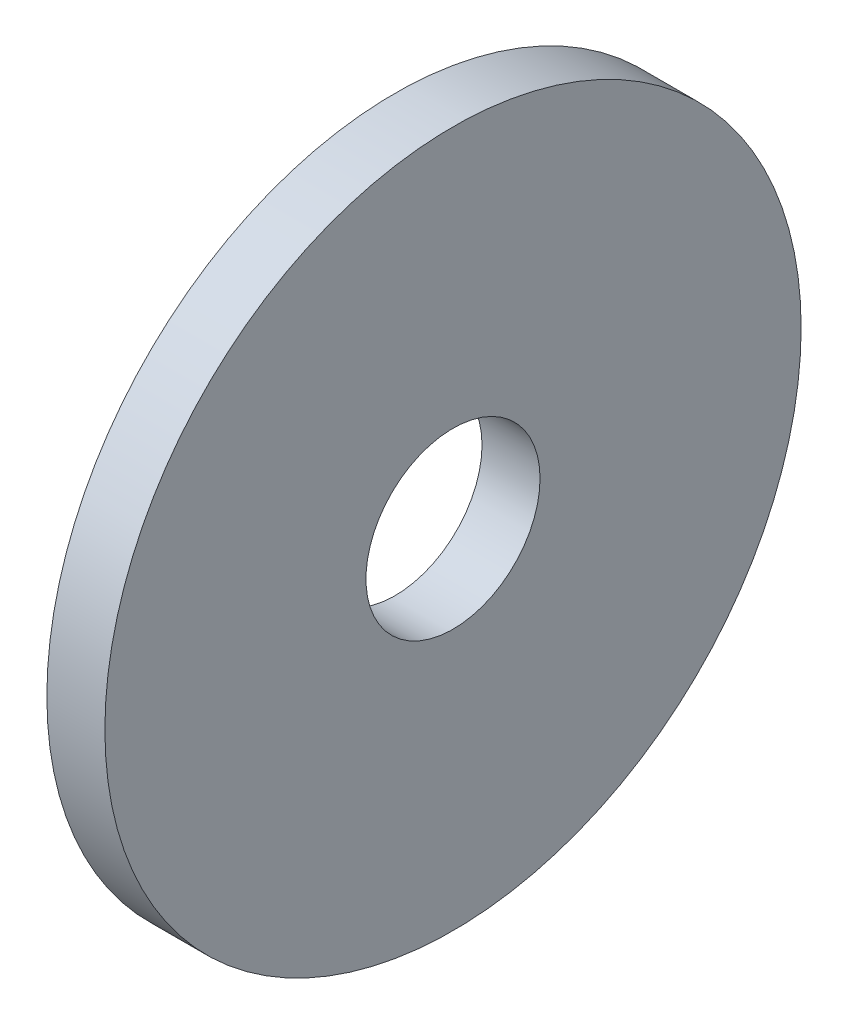
from build123d import *

# Parameters (mm, degrees)
SKETCH1_R               = 12
BOSS_EXTRUDE1_DEPTH     = 2
SKETCH2_R               = 3
CUT_EXTRUDE1_DEPTH      = 1
CUT_EXTRUDE1_DEPTH_BACK = 3


with BuildPart() as part:
    # Sketch1 → Boss-Extrude1 (new body)
    with BuildSketch(Plane(origin=(0, 0, 0), x_dir=(0, 0, -1), z_dir=(1, 0, 0))):
        Circle(SKETCH1_R)
    extrude(amount=BOSS_EXTRUDE1_DEPTH)

    # Sketch2 → Cut-Extrude1 (cut, two sides)
    with BuildSketch(Plane(origin=(2, 0, 0), x_dir=(0, 0, -1), z_dir=(1, 0, 0))) as cut_extrude1_sk:
        Circle(SKETCH2_R)
    extrude(amount=CUT_EXTRUDE1_DEPTH, mode=Mode.SUBTRACT)
    extrude(cut_extrude1_sk.sketch, amount=-CUT_EXTRUDE1_DEPTH_BACK, mode=Mode.SUBTRACT)


solid = part.part
